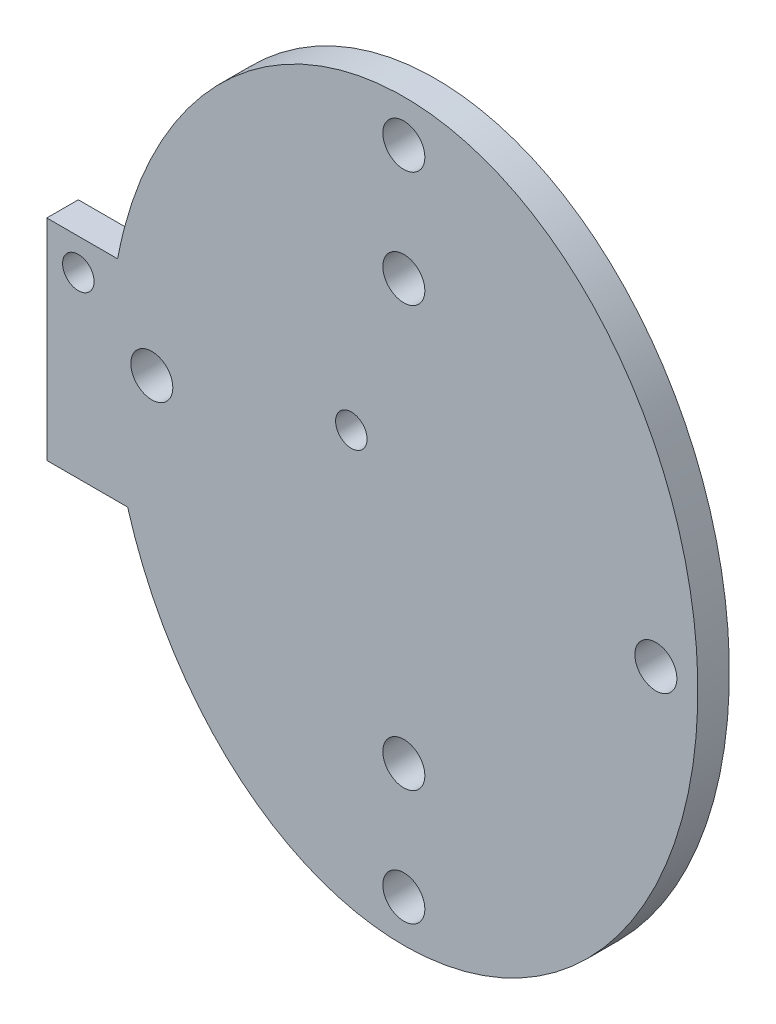
from build123d import *

# Parameters (mm, degrees)
ESQUISSE1_RX            = 35
ESQUISSE1_RY            = 28
ESQUISSE1_R             = 2
BOSS_EXTRU_1_DEPTH      = 3
ESQUISSE2_R             = 2
ENL_V_MAT_EXTRU_1_DEPTH = 10
ESQUISSE4_W             = 8
ESQUISSE4_H             = 20
BOSS_EXTRU_2_DEPTH      = 3
ESQUISSE3_R             = 1.5
ENL_V_MAT_EXTRU_2_DEPTH = 10


with BuildPart() as part:
    # Esquisse1 → Boss.-Extru.1 (new body)
    with BuildSketch(Plane.XY):
        with Locations(Location((0, 0), (0, 0, 90))):
            Ellipse(ESQUISSE1_RX, ESQUISSE1_RY)
        with Locations((0, 20)):
            Circle(ESQUISSE1_R, mode=Mode.SUBTRACT)
        with Locations((0, -20)):
            Circle(ESQUISSE1_R, mode=Mode.SUBTRACT)
    extrude(amount=BOSS_EXTRU_1_DEPTH)

    # Esquisse2 → Enlèv. mat.-Extru.1 (cut)
    with BuildSketch(Plane(origin=(0, 0, 0), x_dir=(-1, 0, 0), z_dir=(0, 0, -1))):
        with Locations((24, 0)):
            Circle(ESQUISSE2_R)
        with Locations((-24, 0)):
            Circle(ESQUISSE2_R)
        with Locations((0, 31)):
            Circle(ESQUISSE2_R)
        with Locations((0, -31)):
            Circle(ESQUISSE2_R)
    extrude(amount=-ENL_V_MAT_EXTRU_1_DEPTH, mode=Mode.SUBTRACT)

    # Esquisse4 → Boss.-Extru.2 (add)
    with BuildSketch(Plane(origin=(0, 0, 0), x_dir=(-1, 0, 0), z_dir=(0, 0, -1))):
        with Locations((30, -2)):
            Rectangle(ESQUISSE4_W, ESQUISSE4_H)
    extrude(amount=-BOSS_EXTRU_2_DEPTH)

    # Esquisse3 → Enlèv. mat.-Extru.2 (cut)
    with BuildSketch(Plane(origin=(0, 0, 0), x_dir=(-1, 0, 0), z_dir=(0, 0, -1))):
        with Locations((5, 5)):
            Circle(ESQUISSE3_R)
        with Locations((31, 5)):
            Circle(ESQUISSE3_R)
    extrude(amount=-ENL_V_MAT_EXTRU_2_DEPTH, mode=Mode.SUBTRACT)


solid = part.part
